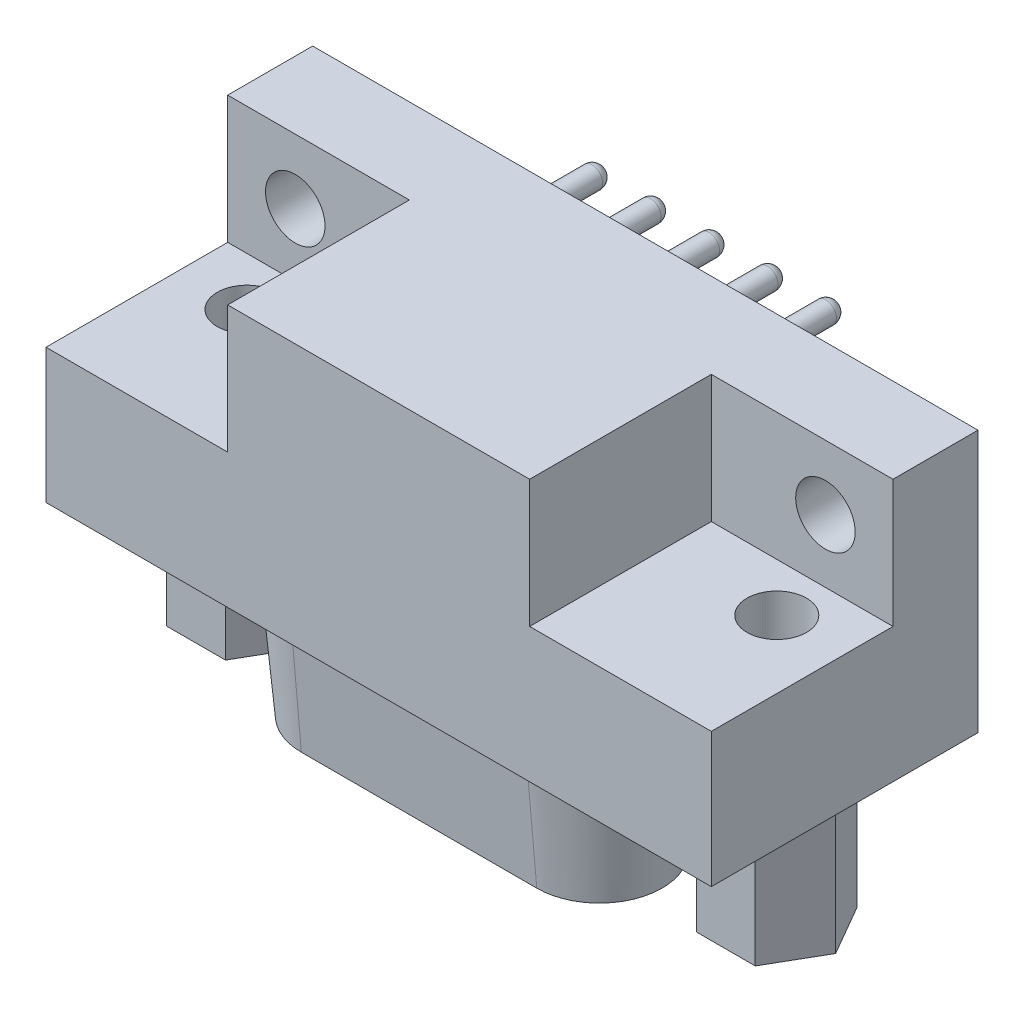
from build123d import *

# Parameters (mm, degrees)
SKETCH1_W                    = 31.31
SKETCH1_H                    = 12.33
BASE_EXTRUDE_DEPTH           = 12.55
SKETCH2_W                    = 8.55
SKETCH2_H                    = 6
CUT_EXTRUDE1_DEPTH           = 8.55
SKETCH3_R                    = 1.4
CUT_EXTRUDE2_DEPTH           = 26.13838897
BOSS_EXTRUDE1_DEPTH          = 6.07
SKETCH5_R                    = 1.4
CUT_EXTRUDE3_DEPTH           = 6.07
BOSS_EXTRUDE2_DEPTH          = 6.07
BOSS_EXTRUDE2_TAPER          = 5
SKETCH12_R                   = 1.4
CUT_EXTRUDE7_DEPTH           = 5
SKETCH7_R                    = 0.5
CUT_EXTRUDE4_DEPTH           = 9.47
CHAMFER2_SIZE                = 0.55
LPATTERN1_COUNT              = 5
LPATTERN1_PITCH              = 2.75
CHAMFER2_OF_LPATTERN1_SIZE   = 0.55
CUT_EXTRUDE5_START           = -9.47
SKETCH8_R                    = 0.5
CUT_EXTRUDE5_DEPTH           = 9.47
CHAMFER3_SIZE                = 0.55
LPATTERN2_COUNT              = 4
LPATTERN2_PITCH              = 2.75
CHAMFER3_OF_LPATTERN2_SIZE   = 0.55
SKETCH9_R                    = 0.5
BOSS_EXTRUDE3_DEPTH          = 3
DOME1_FACE_RADIUS            = 0.5
DOME1_HEIGHT                 = 0.5
LPATTERN3_COUNT              = 5
LPATTERN3_PITCH              = 2.75
LPATTERN3_COPY_1_FACE_RADIUS = 0.5
LPATTERN3_COPY_1_HEIGHT      = 0.5
LPATTERN3_COPY_2_FACE_RADIUS = 0.5
LPATTERN3_COPY_2_HEIGHT      = 0.5
LPATTERN3_COPY_3_FACE_RADIUS = 0.5
LPATTERN3_COPY_3_HEIGHT      = 0.5
LPATTERN3_COPY_4_FACE_RADIUS = 0.5
LPATTERN3_COPY_4_HEIGHT      = 0.5
SKETCH10_R                   = 0.5
BOSS_EXTRUDE4_DEPTH          = 3
DOME2_FACE_RADIUS            = 0.5
DOME2_HEIGHT                 = 0.5
LPATTERN4_COUNT              = 4
LPATTERN4_PITCH              = 2.75
LPATTERN4_COPY_1_FACE_RADIUS = 0.5
LPATTERN4_COPY_1_HEIGHT      = 0.5
LPATTERN4_COPY_2_FACE_RADIUS = 0.5
LPATTERN4_COPY_2_HEIGHT      = 0.5
LPATTERN4_COPY_3_FACE_RADIUS = 0.5
LPATTERN4_COPY_3_HEIGHT      = 0.5
CUT_EXTRUDE6_DEPTH           = 0.001
BODY_MOVE_COPY1_ANGLE        = 180


with BuildPart() as part:
    # Sketch1 → Base-Extrude (new body)
    with BuildSketch(Plane(origin=(0, 0, 0), x_dir=(1, 0, 0), z_dir=(0, 1, 0))):
        with Locations((5.495, 4.395)):
            Rectangle(SKETCH1_W, SKETCH1_H)
    extrude(amount=BASE_EXTRUDE_DEPTH)

    # Sketch2 → Cut-Extrude1 (cut)
    with BuildSketch(Plane(origin=(0, 12.55, 0), x_dir=(-1, 0, 0), z_dir=(0, 1, 0))):
        with Locations((5.885, -1.23)):
            Rectangle(SKETCH2_W, SKETCH2_H)
    cut_extrude1 = extrude(amount=-CUT_EXTRUDE1_DEPTH, mode=Mode.SUBTRACT)

    # Sketch3 → Cut-Extrude2 (cut, through all)
    with BuildSketch(Plane(origin=(0, 4, 0), x_dir=(-1, 0, 0), z_dir=(0, 1, 0))):
        with Locations(Location((6.98, -1.27, 0), (0, 0, 90))):
            Circle(SKETCH3_R)
    cut_extrude2 = extrude(amount=-CUT_EXTRUDE2_DEPTH, mode=Mode.SUBTRACT)

    # Sketch4 → Boss-Extrude1 (add)
    with BuildSketch(Plane(origin=(0, 0, -10.56), x_dir=(-1, 0, 0), z_dir=(0, 0, -1))):
        Polygon((8.355, 3.881109632), (5.585, 3.881109632), (4.2, 6.28), (5.585, 8.678890368), (8.355, 8.678890368), (9.74, 6.28), align=None)
    boss_extrude1 = extrude(amount=BOSS_EXTRUDE1_DEPTH)

    # Sketch5 → Cut-Extrude3 (cut)
    with BuildSketch(Plane(origin=(0, 0, -16.63), x_dir=(-1, 0, 0), z_dir=(0, 0, -1))):
        with Locations((6.97, 6.28)):
            Circle(SKETCH5_R)
    cut_extrude3 = extrude(amount=-CUT_EXTRUDE3_DEPTH, mode=Mode.SUBTRACT)

    # Sketch6 → Boss-Extrude2 (add)
    with BuildSketch(Plane(origin=(0, 0, -10.56), x_dir=(-1, 0, 0), z_dir=(0, 0, -1))):
        with BuildLine():
            ThreePointArc((-11.035, 11.18), (-14.078072176, 9.388227393), (-13.987527475, 5.857995247))
            Line((-13.987527475, 5.857995247), (-12.602527475, 3.637995247))
            ThreePointArc((-12.602527475, 3.637995247), (-11.338227393, 2.436927824), (-9.65, 2))
            Line((-9.65, 2), (-1.34, 2))
            ThreePointArc((-1.34, 2), (0.348227393, 2.436927824), (1.612527475, 3.637995247))
            Line((1.612527475, 3.637995247), (2.997527475, 5.857995247))
            ThreePointArc((2.997527475, 5.857995247), (3.088072176, 9.388227393), (0.045, 11.18))
            Line((0.045, 11.18), (-11.035, 11.18))
        make_face()
    extrude(amount=BOSS_EXTRUDE2_DEPTH, taper=BOSS_EXTRUDE2_TAPER)

    # Sketch12 → Cut-Extrude7 (cut)
    with BuildSketch(Plane.XY.offset(-4.23)):
        with Locations(Location((-6.97, 6.28, 0), (0, 0, 180))):
            Circle(SKETCH12_R)
    cut_extrude7 = extrude(amount=-CUT_EXTRUDE7_DEPTH, mode=Mode.SUBTRACT)

    # Mirror1: Cut-Extrude1, Cut-Extrude2, Boss-Extrude1, Cut-Extrude3, Cut-Extrude7 across plane
    add(cut_extrude1.mirror(Plane.ZY.offset(-5.495)), mode=Mode.SUBTRACT)
    add(cut_extrude2.mirror(Plane.ZY.offset(-5.495)), mode=Mode.SUBTRACT)
    add(boss_extrude1.mirror(Plane.ZY.offset(-5.495)))
    add(cut_extrude3.mirror(Plane.ZY.offset(-5.495)), mode=Mode.SUBTRACT)
    add(cut_extrude7.mirror(Plane.ZY.offset(-5.495)), mode=Mode.SUBTRACT)

    # Sketch7 → Cut-Extrude4 (cut)
    with BuildSketch(Plane(origin=(0, 0, -16.63), x_dir=(-1, 0, 0), z_dir=(0, 0, -1))):
        with Locations((-0.45, 7.69)):
            Circle(SKETCH7_R)
    cut_extrude4 = extrude(amount=-CUT_EXTRUDE4_DEPTH, mode=Mode.SUBTRACT)

    # Chamfer2
    chamfer2_edges = [part.edges().sort_by_distance(p)[0] for p in [
        (0.95, 7.69, -16.63),
    ]]
    chamfer(chamfer2_edges, length=CHAMFER2_SIZE)

    # LPattern1: Cut-Extrude4 ×5
    with Locations(*[(i * LPATTERN1_PITCH, 0, 0) for i in range(1, LPATTERN1_COUNT)]):
        add(cut_extrude4, mode=Mode.SUBTRACT)

    # Chamfer2 of LPattern1
    chamfer2_of_lpattern1_edges = [part.edges().sort_by_distance(p)[0] for p in [
        (3.7, 7.69, -16.63),
        (6.45, 7.69, -16.63),
        (9.2, 7.69, -16.63),
        (11.95, 7.69, -16.63),
    ]]
    chamfer(chamfer2_of_lpattern1_edges, length=CHAMFER2_OF_LPATTERN1_SIZE)

    # Sketch8 → Cut-Extrude5 (cut)
    with BuildSketch(Plane(origin=(0, 0, -16.63), x_dir=(-1, 0, 0), z_dir=(0, 0, -1)).offset(CUT_EXTRUDE5_START)):
        with Locations((-1.825, 4.85)):
            Circle(SKETCH8_R)
    cut_extrude5 = extrude(amount=CUT_EXTRUDE5_DEPTH, mode=Mode.SUBTRACT)

    # Chamfer3
    chamfer3_edges = [part.edges().sort_by_distance(p)[0] for p in [
        (2.325, 4.85, -16.63),
    ]]
    chamfer(chamfer3_edges, length=CHAMFER3_SIZE)

    # LPattern2: Cut-Extrude5 ×4
    with Locations(*[(i * LPATTERN2_PITCH, 0, 0) for i in range(1, LPATTERN2_COUNT)]):
        add(cut_extrude5, mode=Mode.SUBTRACT)

    # Chamfer3 of LPattern2
    chamfer3_of_lpattern2_edges = [part.edges().sort_by_distance(p)[0] for p in [
        (5.075, 4.85, -16.63),
        (7.825, 4.85, -16.63),
        (10.575, 4.85, -16.63),
    ]]
    chamfer(chamfer3_of_lpattern2_edges, length=CHAMFER3_OF_LPATTERN2_SIZE)

    # Sketch9 → Boss-Extrude3 (add)
    with BuildSketch(Plane.XZ):
        with Locations(Location((0, 0, 0), (0, 0, 90))):
            Circle(SKETCH9_R)
    boss_extrude3 = extrude(amount=BOSS_EXTRUDE3_DEPTH)

    # Dome1: a dome of height H over a round flat face of radius A is a cap of a sphere of radius (A * A + H * H) / (2 * H)
    dome1_r = (DOME1_FACE_RADIUS * DOME1_FACE_RADIUS + DOME1_HEIGHT * DOME1_HEIGHT) / (2 * DOME1_HEIGHT)
    dome1_base = Plane((0, -3, 0), z_dir=(0, -1, 0))
    with Locations(dome1_base.offset(DOME1_HEIGHT - dome1_r)):
        dome1_ball = Sphere(dome1_r, mode=Mode.PRIVATE)
    add(split(dome1_ball, bisect_by=dome1_base, keep=Keep.TOP, mode=Mode.PRIVATE))

    # LPattern3: Boss-Extrude3 ×5
    with Locations(*[(i * LPATTERN3_PITCH, 0, 0) for i in range(1, LPATTERN3_COUNT)]):
        add(boss_extrude3)

    # LPattern3 copy 1: a dome of height H over a round flat face of radius A is a cap of a sphere of radius (A * A + H * H) / (2 * H)
    lpattern3_copy_1_r = (LPATTERN3_COPY_1_FACE_RADIUS * LPATTERN3_COPY_1_FACE_RADIUS + LPATTERN3_COPY_1_HEIGHT * LPATTERN3_COPY_1_HEIGHT) / (2 * LPATTERN3_COPY_1_HEIGHT)
    lpattern3_copy_1_base = Plane((2.75, -3, 0), z_dir=(0, -1, 0))
    with Locations(lpattern3_copy_1_base.offset(LPATTERN3_COPY_1_HEIGHT - lpattern3_copy_1_r)):
        lpattern3_copy_1_ball = Sphere(lpattern3_copy_1_r, mode=Mode.PRIVATE)
    add(split(lpattern3_copy_1_ball, bisect_by=lpattern3_copy_1_base, keep=Keep.TOP, mode=Mode.PRIVATE))

    # LPattern3 copy 2: a dome of height H over a round flat face of radius A is a cap of a sphere of radius (A * A + H * H) / (2 * H)
    lpattern3_copy_2_r = (LPATTERN3_COPY_2_FACE_RADIUS * LPATTERN3_COPY_2_FACE_RADIUS + LPATTERN3_COPY_2_HEIGHT * LPATTERN3_COPY_2_HEIGHT) / (2 * LPATTERN3_COPY_2_HEIGHT)
    lpattern3_copy_2_base = Plane((5.5, -3, 0), z_dir=(0, -1, 0))
    with Locations(lpattern3_copy_2_base.offset(LPATTERN3_COPY_2_HEIGHT - lpattern3_copy_2_r)):
        lpattern3_copy_2_ball = Sphere(lpattern3_copy_2_r, mode=Mode.PRIVATE)
    add(split(lpattern3_copy_2_ball, bisect_by=lpattern3_copy_2_base, keep=Keep.TOP, mode=Mode.PRIVATE))

    # LPattern3 copy 3: a dome of height H over a round flat face of radius A is a cap of a sphere of radius (A * A + H * H) / (2 * H)
    lpattern3_copy_3_r = (LPATTERN3_COPY_3_FACE_RADIUS * LPATTERN3_COPY_3_FACE_RADIUS + LPATTERN3_COPY_3_HEIGHT * LPATTERN3_COPY_3_HEIGHT) / (2 * LPATTERN3_COPY_3_HEIGHT)
    lpattern3_copy_3_base = Plane((8.25, -3, 0), z_dir=(0, -1, 0))
    with Locations(lpattern3_copy_3_base.offset(LPATTERN3_COPY_3_HEIGHT - lpattern3_copy_3_r)):
        lpattern3_copy_3_ball = Sphere(lpattern3_copy_3_r, mode=Mode.PRIVATE)
    add(split(lpattern3_copy_3_ball, bisect_by=lpattern3_copy_3_base, keep=Keep.TOP, mode=Mode.PRIVATE))

    # LPattern3 copy 4: a dome of height H over a round flat face of radius A is a cap of a sphere of radius (A * A + H * H) / (2 * H)
    lpattern3_copy_4_r = (LPATTERN3_COPY_4_FACE_RADIUS * LPATTERN3_COPY_4_FACE_RADIUS + LPATTERN3_COPY_4_HEIGHT * LPATTERN3_COPY_4_HEIGHT) / (2 * LPATTERN3_COPY_4_HEIGHT)
    lpattern3_copy_4_base = Plane((11, -3, 0), z_dir=(0, -1, 0))
    with Locations(lpattern3_copy_4_base.offset(LPATTERN3_COPY_4_HEIGHT - lpattern3_copy_4_r)):
        lpattern3_copy_4_ball = Sphere(lpattern3_copy_4_r, mode=Mode.PRIVATE)
    add(split(lpattern3_copy_4_ball, bisect_by=lpattern3_copy_4_base, keep=Keep.TOP, mode=Mode.PRIVATE))

    # Sketch10 → Boss-Extrude4 (add)
    with BuildSketch(Plane.XZ):
        with Locations(Location((1.375, -2.84, 0), (0, 0, 90))):
            Circle(SKETCH10_R)
    boss_extrude4 = extrude(amount=BOSS_EXTRUDE4_DEPTH)

    # Dome2: a dome of height H over a round flat face of radius A is a cap of a sphere of radius (A * A + H * H) / (2 * H)
    dome2_r = (DOME2_FACE_RADIUS * DOME2_FACE_RADIUS + DOME2_HEIGHT * DOME2_HEIGHT) / (2 * DOME2_HEIGHT)
    dome2_base = Plane((1.375, -3, -2.84), z_dir=(0, -1, 0))
    with Locations(dome2_base.offset(DOME2_HEIGHT - dome2_r)):
        dome2_ball = Sphere(dome2_r, mode=Mode.PRIVATE)
    add(split(dome2_ball, bisect_by=dome2_base, keep=Keep.TOP, mode=Mode.PRIVATE))

    # LPattern4: Boss-Extrude4 ×4
    with Locations(*[(i * LPATTERN4_PITCH, 0, 0) for i in range(1, LPATTERN4_COUNT)]):
        add(boss_extrude4)

    # LPattern4 copy 1: a dome of height H over a round flat face of radius A is a cap of a sphere of radius (A * A + H * H) / (2 * H)
    lpattern4_copy_1_r = (LPATTERN4_COPY_1_FACE_RADIUS * LPATTERN4_COPY_1_FACE_RADIUS + LPATTERN4_COPY_1_HEIGHT * LPATTERN4_COPY_1_HEIGHT) / (2 * LPATTERN4_COPY_1_HEIGHT)
    lpattern4_copy_1_base = Plane((4.125, -3, -2.84), z_dir=(0, -1, 0))
    with Locations(lpattern4_copy_1_base.offset(LPATTERN4_COPY_1_HEIGHT - lpattern4_copy_1_r)):
        lpattern4_copy_1_ball = Sphere(lpattern4_copy_1_r, mode=Mode.PRIVATE)
    add(split(lpattern4_copy_1_ball, bisect_by=lpattern4_copy_1_base, keep=Keep.TOP, mode=Mode.PRIVATE))

    # LPattern4 copy 2: a dome of height H over a round flat face of radius A is a cap of a sphere of radius (A * A + H * H) / (2 * H)
    lpattern4_copy_2_r = (LPATTERN4_COPY_2_FACE_RADIUS * LPATTERN4_COPY_2_FACE_RADIUS + LPATTERN4_COPY_2_HEIGHT * LPATTERN4_COPY_2_HEIGHT) / (2 * LPATTERN4_COPY_2_HEIGHT)
    lpattern4_copy_2_base = Plane((6.875, -3, -2.84), z_dir=(0, -1, 0))
    with Locations(lpattern4_copy_2_base.offset(LPATTERN4_COPY_2_HEIGHT - lpattern4_copy_2_r)):
        lpattern4_copy_2_ball = Sphere(lpattern4_copy_2_r, mode=Mode.PRIVATE)
    add(split(lpattern4_copy_2_ball, bisect_by=lpattern4_copy_2_base, keep=Keep.TOP, mode=Mode.PRIVATE))

    # LPattern4 copy 3: a dome of height H over a round flat face of radius A is a cap of a sphere of radius (A * A + H * H) / (2 * H)
    lpattern4_copy_3_r = (LPATTERN4_COPY_3_FACE_RADIUS * LPATTERN4_COPY_3_FACE_RADIUS + LPATTERN4_COPY_3_HEIGHT * LPATTERN4_COPY_3_HEIGHT) / (2 * LPATTERN4_COPY_3_HEIGHT)
    lpattern4_copy_3_base = Plane((9.625, -3, -2.84), z_dir=(0, -1, 0))
    with Locations(lpattern4_copy_3_base.offset(LPATTERN4_COPY_3_HEIGHT - lpattern4_copy_3_r)):
        lpattern4_copy_3_ball = Sphere(lpattern4_copy_3_r, mode=Mode.PRIVATE)
    add(split(lpattern4_copy_3_ball, bisect_by=lpattern4_copy_3_base, keep=Keep.TOP, mode=Mode.PRIVATE))

    # Sketch11 → Cut-Extrude6 (cut)
    with BuildSketch(Plane(origin=(0, 0, -16.63), x_dir=(-1, 0, 0), z_dir=(0, 0, -1))):
        with BuildLine():
            Line((0.822593861, 4.13081419), (2.207593861, 6.35081419))
            ThreePointArc((2.207593861, 6.35081419), (2.273913792, 8.936550795), (0.045, 10.248943812))
            Line((0.045, 10.248943812), (-11.035, 10.248943812))
            ThreePointArc((-11.035, 10.248943812), (-13.263913792, 8.936550795), (-13.197593861, 6.35081419))
            Line((-13.197593861, 6.35081419), (-11.812593861, 4.13081419))
            ThreePointArc((-11.812593861, 4.13081419), (-10.886550795, 3.251086208), (-9.65, 2.931056188))
            Line((-9.65, 2.931056188), (-1.34, 2.931056188))
            ThreePointArc((-1.34, 2.931056188), (-0.103449205, 3.251086208), (0.822593861, 4.13081419))
        make_face()
    extrude(amount=-CUT_EXTRUDE6_DEPTH, mode=Mode.SUBTRACT)


with BuildPart() as part_1:
    # Body-Move_Copy1: moved
    add(part.part.rotate(Axis((0, 0, 0), (1.462460244036131e-13, 0.7071067811865841, 0.7071067811865109)), BODY_MOVE_COPY1_ANGLE))


solid = part_1.part
